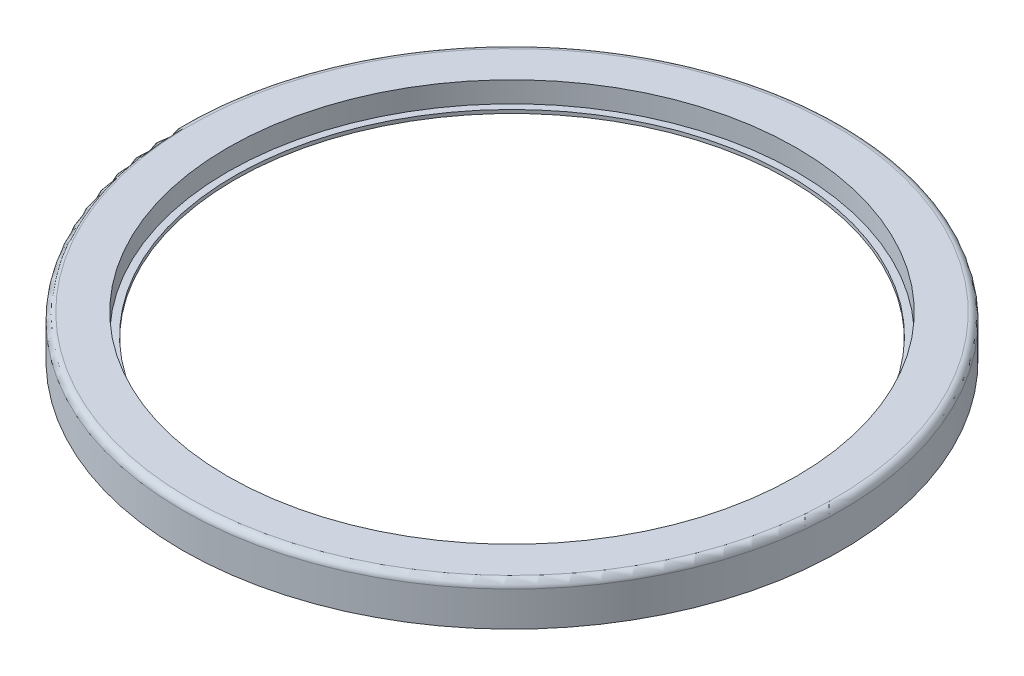
from build123d import *

# Parameters (mm, degrees)
SKETCH1_R           = 47.5
BOSS_EXTRUDE1_DEPTH = 2
SKETCH2_R           = 42.25
BOSS_EXTRUDE2_DEPTH = 1.5
BOSS_EXTRUDE2_TAPER = 2
SKETCH5_R           = 10
CUT_EXTRUDE1_DEPTH  = 4
CHAMFER1_SIZE       = 1
SKETCH7_R           = 47.5
SKETCH7_R_2         = 45.7
BOSS_EXTRUDE3_DEPTH = 4
FILLET2_R           = 1
SKETCH8_R           = 41
CUT_EXTRUDE4_DEPTH  = 3
SKETCH9_R           = 40
CUT_EXTRUDE5_DEPTH  = 5
SKETCH10_R          = 45.7
SKETCH10_R_2        = 45.2
BOSS_EXTRUDE4_DEPTH = 1.5


with BuildPart() as part:
    # Sketch1 → Boss-Extrude1 (new body)
    with BuildSketch(Plane(origin=(0, 0, 0), x_dir=(1, 0, 0), z_dir=(0, 1, 0))):
        Circle(SKETCH1_R)
    extrude(amount=BOSS_EXTRUDE1_DEPTH)

    # Sketch2 → Boss-Extrude2 (add)
    with BuildSketch(Plane.XZ):
        Circle(SKETCH2_R)
    extrude(amount=BOSS_EXTRUDE2_DEPTH, taper=BOSS_EXTRUDE2_TAPER)

    # Sketch5 → Cut-Extrude1 (cut)
    with BuildSketch(Plane(origin=(0, 2, 0), x_dir=(1, 0, 0), z_dir=(0, 1, 0))):
        Circle(SKETCH5_R)
    extrude(amount=-CUT_EXTRUDE1_DEPTH, mode=Mode.SUBTRACT)

    # Chamfer1
    chamfer1_edges = [part.edges().sort_by_distance(p)[0] for p in [
        (-10, -1.5, 0),
        (-10, 2, 0),
    ]]
    chamfer(chamfer1_edges, length=CHAMFER1_SIZE)

    # Sketch7 → Boss-Extrude3 (add)
    with BuildSketch(Plane.XZ):
        Circle(SKETCH7_R)
        Circle(SKETCH7_R_2, mode=Mode.SUBTRACT)
    extrude(amount=BOSS_EXTRUDE3_DEPTH)

    # Fillet2
    fillet2_edges = [part.edges().sort_by_distance(p)[0] for p in [
        (-47.5, 2, 0),
    ]]
    fillet(fillet2_edges, radius=FILLET2_R)

    # Sketch8 → Cut-Extrude4 (cut)
    with BuildSketch(Plane(origin=(0, 2, 0), x_dir=(1, 0, 0), z_dir=(0, 1, 0))):
        Circle(SKETCH8_R)
    extrude(amount=-CUT_EXTRUDE4_DEPTH, mode=Mode.SUBTRACT)

    # Sketch9 → Cut-Extrude5 (cut)
    with BuildSketch(Plane(origin=(0, -1, 0), x_dir=(1, 0, 0), z_dir=(0, 1, 0))):
        Circle(SKETCH9_R)
    extrude(amount=-CUT_EXTRUDE5_DEPTH, mode=Mode.SUBTRACT)

    # Sketch10 → Boss-Extrude4 (add)
    with BuildSketch(Plane.XZ.offset(4)):
        Circle(SKETCH10_R)
        Circle(SKETCH10_R_2, mode=Mode.SUBTRACT)
    extrude(amount=-BOSS_EXTRUDE4_DEPTH)


solid = part.part
